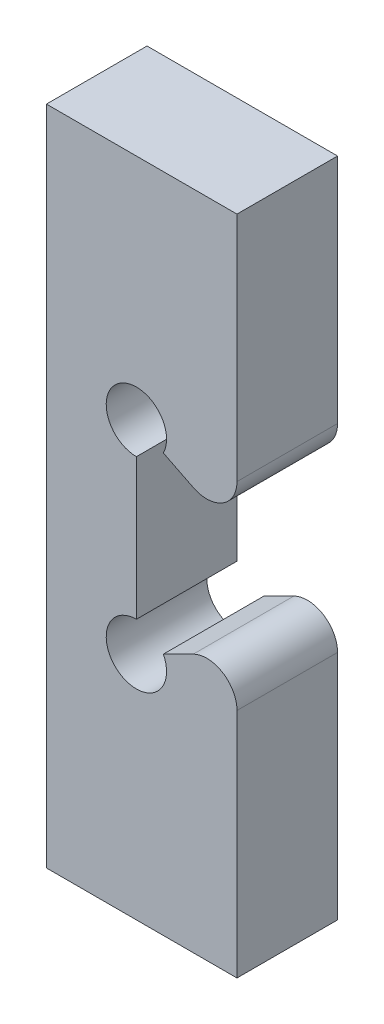
from build123d import *

# Parameters (mm, degrees)
SALIENTE_EXTRUIR1_DEPTH = 5


with BuildPart() as part:
    # Croquis1 → Saliente-Extruir1 (new body)
    with BuildSketch(Plane.XY):
        with BuildLine():
            Line((-64, 25.6), (-73.471195353, 25.6))
            Line((-73.471195353, 25.6), (-73.471195353, -7.284781413))
            Line((-73.471195353, -7.284781413), (-64, -7.284781413))
            Line((-64, -7.284781413), (-64, 4.23055831))
            ThreePointArc((-64, 4.23055831), (-64.711403332, 5.506534523), (-66.170820393, 5.572199097))
            Line((-66.170820393, 5.572199097), (-67.658359214, 4.828429687))
            ThreePointArc((-67.658359214, 4.828429687), (-69.788596668, 2.881633081), (-69, 5.657609293))
            Line((-69, 5.657609293), (-69, 12.657609293))
            ThreePointArc((-69, 12.657609293), (-69.788596668, 15.433585506), (-67.658359214, 13.4867889))
            Line((-67.658359214, 13.4867889), (-66.170820393, 12.74301949))
            ThreePointArc((-66.170820393, 12.74301949), (-64.711403332, 12.808684064), (-64, 14.084660276))
            Line((-64, 14.084660276), (-64, 25.6))
        make_face()
    extrude(amount=-SALIENTE_EXTRUIR1_DEPTH)


solid = part.part
